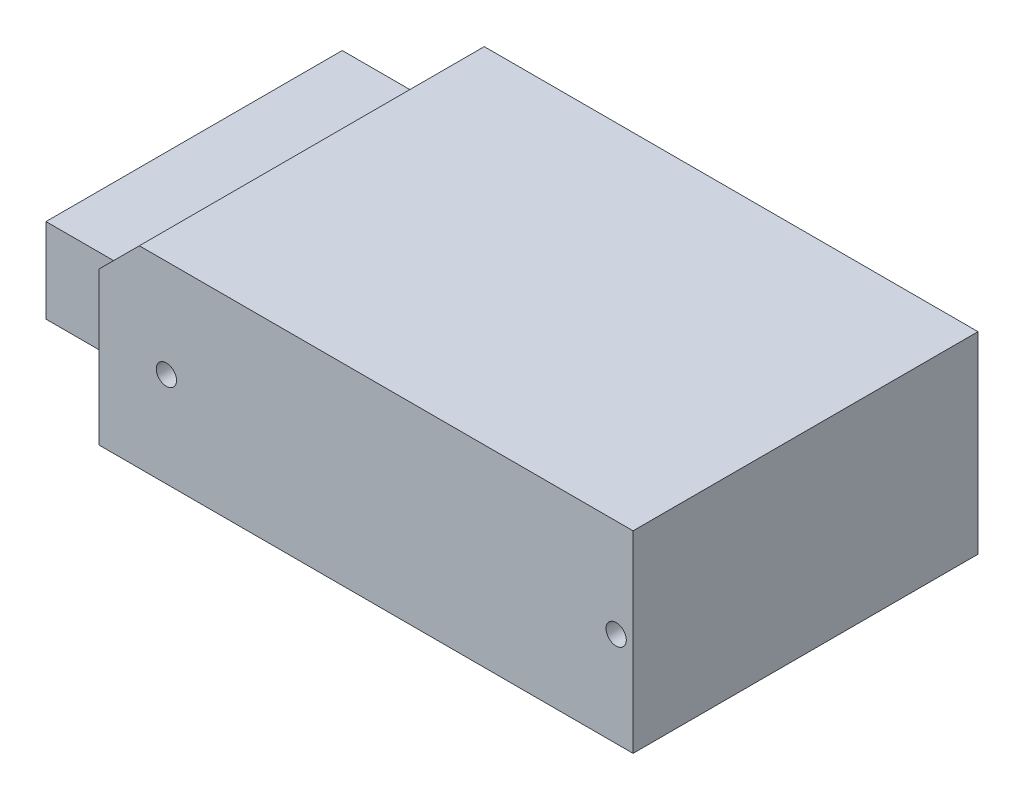
from build123d import *

# Parameters (mm, degrees)
SKETCH1_W           = 79
SKETCH1_H           = 51
BOSS_EXTRUDE1_DEPTH = 28.5
SKETCH2_W           = 43.8
SKETCH2_H           = 12.5
BOSS_EXTRUDE2_DEPTH = 15
CUT_EXTRUDE1_DEPTH  = 52
SKETCH4_R           = 1.5
CUT_EXTRUDE2_DEPTH  = 15
SKETCH5_R           = 1.5
CUT_EXTRUDE3_DEPTH  = 15


with BuildPart() as part:
    # Sketch1 → Boss-Extrude1 (new body)
    with BuildSketch(Plane(origin=(0, 0, 0), x_dir=(1, 0, 0), z_dir=(0, 1, 0))):
        Rectangle(SKETCH1_W, SKETCH1_H)
    extrude(amount=BOSS_EXTRUDE1_DEPTH)

    # Sketch2 → Boss-Extrude2 (add)
    with BuildSketch(Plane.ZY.offset(39.5)):
        with Locations((-3.6, 11.25)):
            Rectangle(SKETCH2_W, SKETCH2_H)
    extrude(amount=BOSS_EXTRUDE2_DEPTH)

    # Sketch3 → Cut-Extrude1 (cut, through all)
    with BuildSketch(Plane.XY.offset(25.5)):
        Polygon((-39.5, 28.5), (-39.5, 22.5), (-33.5, 28.5), align=None)
    extrude(amount=-CUT_EXTRUDE1_DEPTH, mode=Mode.SUBTRACT)

    # Sketch4 → Cut-Extrude2 (cut)
    with BuildSketch(Plane.XY.offset(25.5)):
        with Locations((-29.5, 14)):
            Circle(SKETCH4_R)
        with Locations((37, 14)):
            Circle(SKETCH4_R)
    extrude(amount=-CUT_EXTRUDE2_DEPTH, mode=Mode.SUBTRACT)

    # Sketch5 → Cut-Extrude3 (cut)
    with BuildSketch(Plane.XZ):
        with Locations((-26, 0)):
            Circle(SKETCH5_R)
        with Locations((29, 0)):
            Circle(SKETCH5_R)
    extrude(amount=-CUT_EXTRUDE3_DEPTH, mode=Mode.SUBTRACT)


solid = part.part
